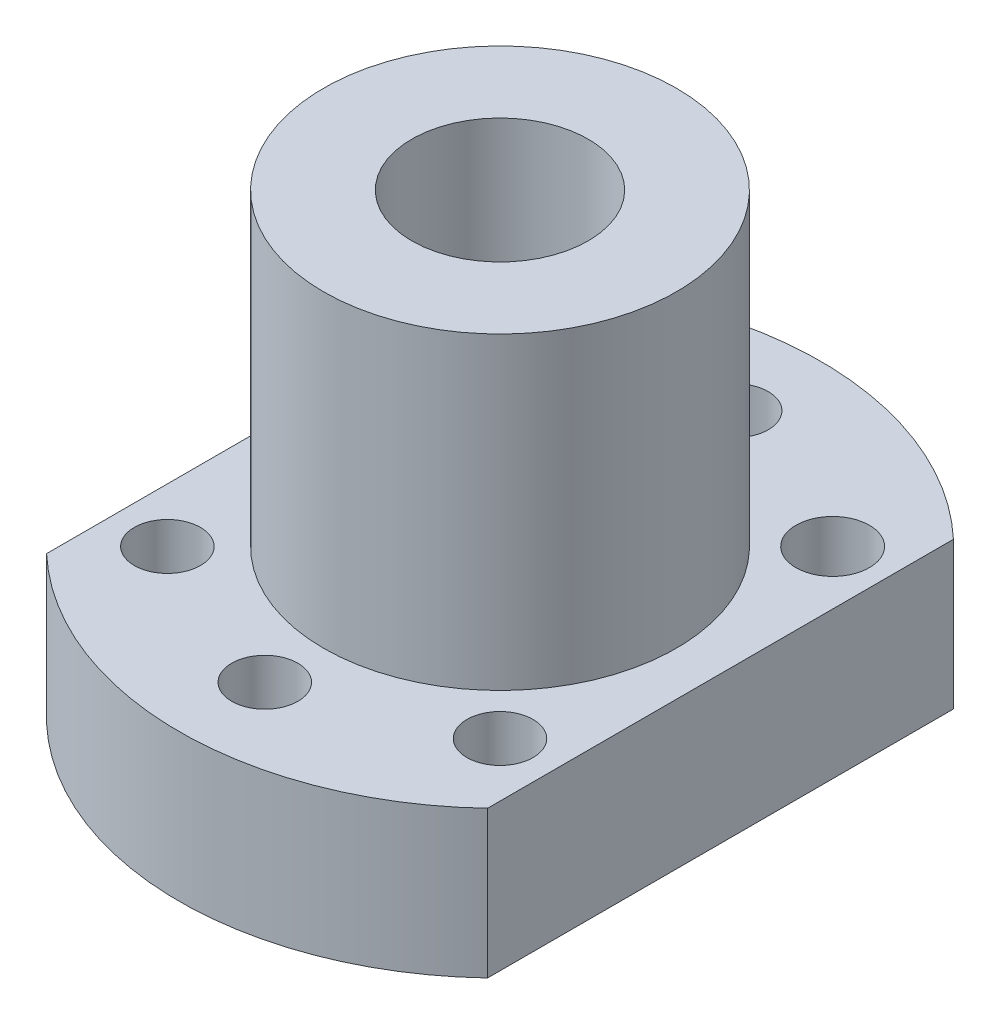
from build123d import *

# Parameters (mm, degrees)
SKETCH_1_R      = 6
EXTRUDE_1_DEPTH = 10
SKETCH_3_R      = 12
SKETCH_3_R_2    = 6
EXTRUDE_2_DEPTH = 21


with BuildPart() as part:
    # 草图1 → 凸台-拉伸1 (new body)
    with BuildSketch(Plane(origin=(0, 0, 0), x_dir=(1, 0, 0), z_dir=(0, 1, 0))):
        with BuildLine():
            ThreePointArc((-12.788894575, 9.614789418), (-14.041020916, 7.671357874), (-15, 5.567764363))
            Line((-15, 5.567764363), (-15, -5.567764363))
            ThreePointArc((-15, -5.567764363), (-14.041020916, -7.671357874), (-12.788894575, -9.614789418))
            ThreePointArc((-12.788894575, -9.614789418), (-10.380078131, -9.26655576), (-9.063708499, -11.313708499))
            ThreePointArc((-9.063708499, -11.313708499), (-9.205976551, -12.101087718), (-9.614789418, -12.788894575))
            ThreePointArc((-9.614789418, -12.788894575), (-6.122934918, -14.78207252), (-2.24443128, -15.841796875))
            ThreePointArc((-2.24443128, -15.841796875), (0, -13.75), (2.24443128, -15.841796875))
            ThreePointArc((2.24443128, -15.841796875), (6.122934918, -14.78207252), (9.614789418, -12.788894575))
            ThreePointArc((9.614789418, -12.788894575), (9.722718241, -9.722718241), (12.788894575, -9.614789418))
            ThreePointArc((12.788894575, -9.614789418), (14.041020916, -7.671357874), (15, -5.567764363))
            Line((15, -5.567764363), (15, 5.567764363))
            ThreePointArc((15, 5.567764363), (14.100687822, 7.561124451), (12.937965605, 9.413237806))
            ThreePointArc((12.937965605, 9.413237806), (9.545941546, 9.545941546), (9.413237806, 12.937965605))
            ThreePointArc((9.413237806, 12.937965605), (6.006943578, 14.829586267), (2.24443128, 15.841796875))
            ThreePointArc((2.24443128, 15.841796875), (0, 13.75), (-2.24443128, 15.841796875))
            ThreePointArc((-2.24443128, 15.841796875), (-6.122934918, 14.78207252), (-9.614789418, 12.788894575))
            ThreePointArc((-9.614789418, 12.788894575), (-9.205976551, 12.101087718), (-9.063708499, 11.313708499))
            ThreePointArc((-9.063708499, 11.313708499), (-10.380078131, 9.26655576), (-12.788894575, 9.614789418))
        make_face()
        Circle(SKETCH_1_R, mode=Mode.SUBTRACT)
        with BuildLine():
            Line((-15, -5.567764363), (-15, -15.84625977))
            ThreePointArc((-15, -15.84625977), (0, -21.819806339), (15, -15.84625977))
            Line((15, -15.84625977), (15, -5.567764363))
            ThreePointArc((15, -5.567764363), (14.041020916, -7.671357874), (12.788894575, -9.614789418))
            ThreePointArc((12.788894575, -9.614789418), (13.360861238, -10.380078131), (13.563708499, -11.313708499))
            ThreePointArc((13.563708499, -11.313708499), (12.101087718, -13.421440447), (9.614789418, -12.788894575))
            ThreePointArc((9.614789418, -12.788894575), (6.122934918, -14.78207252), (2.24443128, -15.841796875))
            ThreePointArc((2.24443128, -15.841796875), (2.248607389, -15.920849448), (2.25, -16))
            ThreePointArc((2.25, -16), (-0.079150552, -18.248607389), (-2.24443128, -15.841796875))
            ThreePointArc((-2.24443128, -15.841796875), (-6.122934918, -14.78207252), (-9.614789418, -12.788894575))
            ThreePointArc((-9.614789418, -12.788894575), (-12.904698757, -12.904698757), (-12.788894575, -9.614789418))
            ThreePointArc((-12.788894575, -9.614789418), (-14.041020916, -7.671357874), (-15, -5.567764363))
        make_face()
        with BuildLine():
            ThreePointArc((15, 15.84625977), (0, 21.819806339), (-15, 15.84625977))
            Line((-15, 15.84625977), (-15, 5.567764363))
            ThreePointArc((-15, 5.567764363), (-14.041020916, 7.671357874), (-12.788894575, 9.614789418))
            ThreePointArc((-12.788894575, 9.614789418), (-12.904698757, 12.904698757), (-9.614789418, 12.788894575))
            ThreePointArc((-9.614789418, 12.788894575), (-6.122934918, 14.78207252), (-2.24443128, 15.841796875))
            ThreePointArc((-2.24443128, 15.841796875), (-0.079150552, 18.248607389), (2.25, 16))
            ThreePointArc((2.25, 16), (2.248607389, 15.920849448), (2.24443128, 15.841796875))
            ThreePointArc((2.24443128, 15.841796875), (6.006943578, 14.829586267), (9.413237806, 12.937965605))
            ThreePointArc((9.413237806, 12.937965605), (12.179394143, 13.659041816), (13.813708499, 11.313708499))
            ThreePointArc((13.813708499, 11.313708499), (13.584241781, 10.267439596), (12.937965605, 9.413237806))
            ThreePointArc((12.937965605, 9.413237806), (14.100687822, 7.561124451), (15, 5.567764363))
            Line((15, 5.567764363), (15, 15.84625977))
        make_face()
    extrude(amount=EXTRUDE_1_DEPTH)

    # 草图3 → 凸台-拉伸2 (add)
    with BuildSketch(Plane(origin=(0, 10, 0), x_dir=(1, 0, 0), z_dir=(0, 1, 0))):
        Circle(SKETCH_3_R)
        Circle(SKETCH_3_R_2, mode=Mode.SUBTRACT)
    extrude(amount=EXTRUDE_2_DEPTH)


solid = part.part
